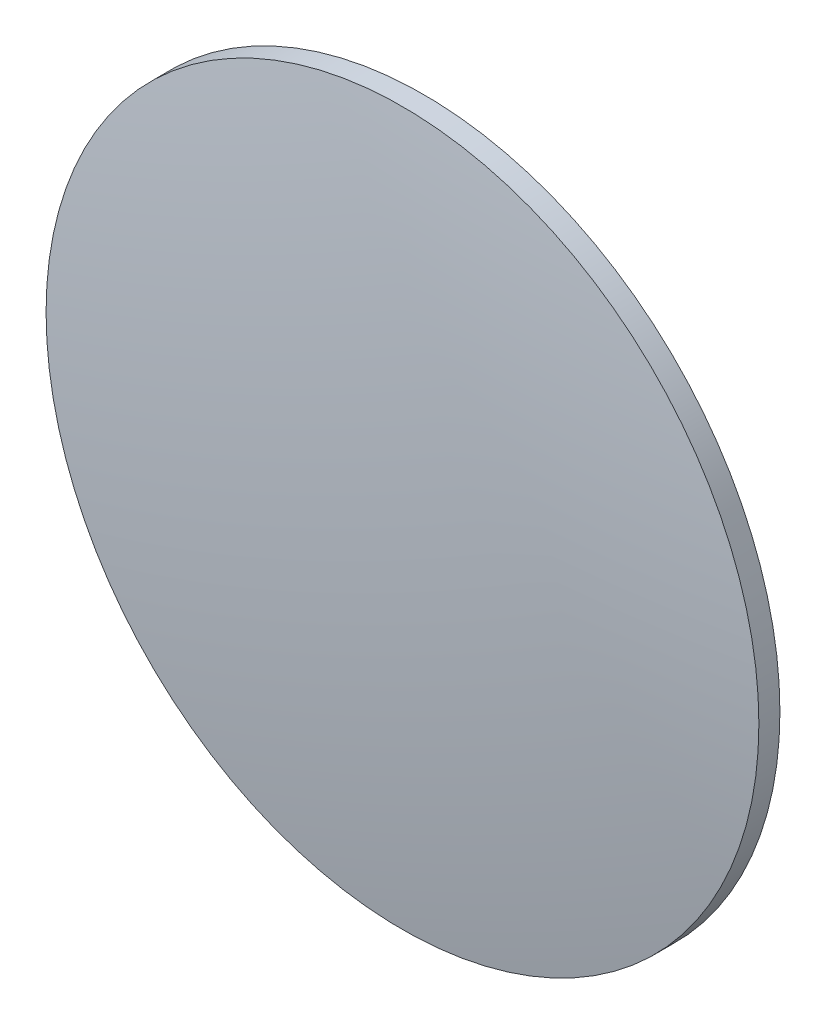
from build123d import *

# Parameters (mm, degrees)
SKETCH2_R          = 182.571
SKETCH2_R_2        = 25.4
CUT_EXTRUDE1_DEPTH = 366.142
SKETCH3_R          = 25.4
CUT_EXTRUDE3_DEPTH = 362.867


with BuildPart() as part:
    # Sketch1 → Revolve1 (revolve)
    with BuildSketch(Plane.XY):
        with BuildLine():
            Line((0, 182.571), (0, -182.571))
            ThreePointArc((0, -182.571), (-182.571, 0), (0, 182.571))
        make_face()
    revolve(axis=Axis((0, 182.571, 0), (0, -1, 0)))

    # Sketch2 → Cut-Extrude1 (cut, through all)
    with BuildSketch(Plane.XY.offset(182.571)):
        Circle(SKETCH2_R)
        Circle(SKETCH2_R_2, mode=Mode.SUBTRACT)
    extrude(amount=-CUT_EXTRUDE1_DEPTH, mode=Mode.SUBTRACT)

    # Sketch3 → Cut-Extrude3 (cut, through all)
    with BuildSketch(Plane.XY.offset(179.296)):
        Circle(SKETCH3_R)
    extrude(amount=-CUT_EXTRUDE3_DEPTH, mode=Mode.SUBTRACT)


solid = part.part
